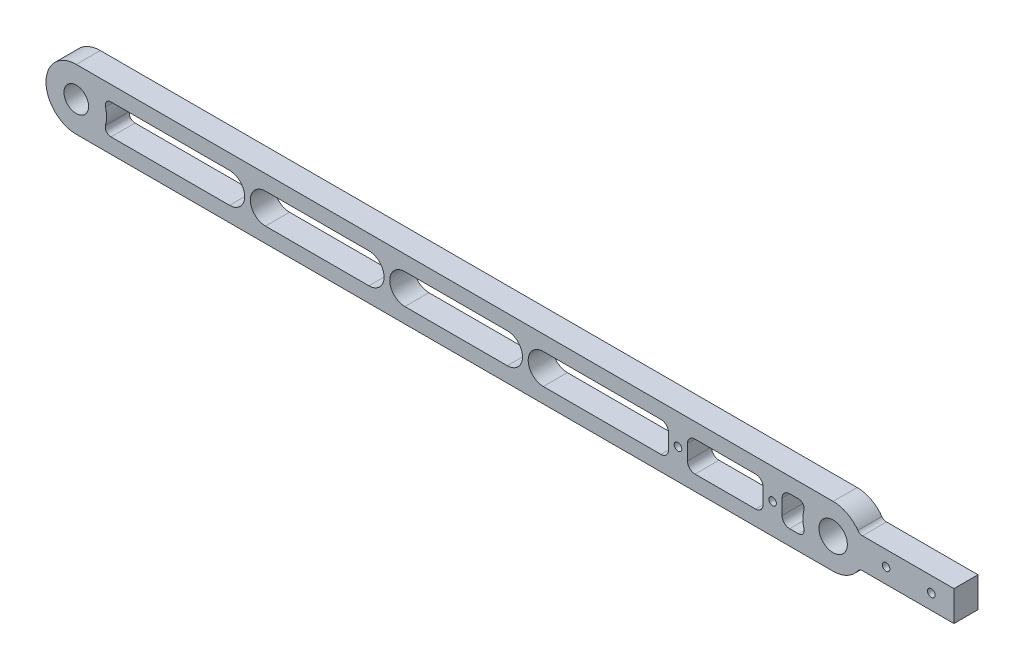
from build123d import *

# Parameters (mm, degrees)
SKETCH1_R           = 1
SKETCH1_R_2         = 3.25
SKETCH1_R_3         = 3.75
BOSS_EXTRUDE1_DEPTH = 6.35


with BuildPart() as part:
    # Sketch1 → Boss-Extrude1 (new body)
    with BuildSketch(Plane(origin=(0, 0, 0), x_dir=(-1, 0, 0), z_dir=(0, 0, -1))):
        with BuildLine():
            Line((0, 8), (-200, 8))
            ThreePointArc((-200, 8), (-203.670651742, 7.108186533), (-206.52291932, 4.631578948))
            ThreePointArc((-206.52291932, 4.631578948), (-207.05771949, 4.167215025), (-207.745966692, 4))
            Line((-207.745966692, 4), (-231.92820323, 4))
            Line((-231.92820323, 4), (-231.92820323, -4))
            Line((-231.92820323, -4), (-207.745966692, -4))
            ThreePointArc((-207.745966692, -4), (-207.05771949, -4.167215025), (-206.52291932, -4.631578947))
            ThreePointArc((-206.52291932, -4.631578947), (-203.670651742, -7.108186533), (-200, -8))
            Line((-200, -8), (0, -8))
            ThreePointArc((0, -8), (8, 0), (0, 8))
        make_face()
        with Locations((-159, 0)):
            Circle(SKETCH1_R, mode=Mode.SUBTRACT)
        with Locations((-184, 0)):
            Circle(SKETCH1_R, mode=Mode.SUBTRACT)
        Circle(SKETCH1_R_2, mode=Mode.SUBTRACT)
        with Locations((-200, 0)):
            Circle(SKETCH1_R_3, mode=Mode.SUBTRACT)
        with Locations((-213.982050808, 0)):
            Circle(SKETCH1_R, mode=Mode.SUBTRACT)
        with Locations((-225.946152423, 0)):
            Circle(SKETCH1_R, mode=Mode.SUBTRACT)
        with BuildLine():
            Line((-186.499999983, 1.999999984), (-186.499999983, -1.999999983))
            ThreePointArc((-186.499999983, -1.999999983), (-187.085786426, -3.414213557), (-188.5, -4))
            Line((-188.5, -4), (-190.83484861, -4))
            ThreePointArc((-190.83484861, -4), (-192.026927731, -3.410465468), (-192.281977777, -2.105263158))
            ThreePointArc((-192.281977777, -2.105263158), (-192, 0), (-192.281977777, 2.105263158))
            ThreePointArc((-192.281977777, 2.105263158), (-192.026927731, 3.410465468), (-190.83484861, 4))
            Line((-190.83484861, 4), (-188.5, 4))
            ThreePointArc((-188.5, 4), (-187.085786426, 3.414213558), (-186.499999983, 1.999999984))
        make_face(mode=Mode.SUBTRACT)
        with BuildLine():
            Line((-181.499999977, -2.000000023), (-181.499999977, 2.000000023))
            ThreePointArc((-181.499999977, 2.000000023), (-180.914213546, 3.414213569), (-179.5, 4))
            Line((-179.5, 4), (-163.5, 4))
            ThreePointArc((-163.5, 4), (-162.085786447, 3.414213567), (-161.500000014, 2.000000014))
            Line((-161.500000014, 2.000000014), (-161.500000014, -2.000000014))
            ThreePointArc((-161.500000014, -2.000000014), (-162.085786447, -3.414213566), (-163.5, -4))
            Line((-163.5, -4), (-179.5, -4))
            ThreePointArc((-179.5, -4), (-180.914213546, -3.414213569), (-181.499999977, -2.000000023))
        make_face(mode=Mode.SUBTRACT)
        with BuildLine():
            Line((-49.998863542, -4), (-77.332575695, -4))
            ThreePointArc((-77.332575695, -4), (-81.332575695, 0), (-77.332575695, 4))
            Line((-77.332575695, 4), (-49.998863542, 4))
            ThreePointArc((-49.998863542, 4), (-45.998863542, 0), (-49.998863542, -4))
        make_face(mode=Mode.SUBTRACT)
        with BuildLine():
            Line((-123.416287847, -4), (-154.5, -4))
            ThreePointArc((-154.5, -4), (-155.914213568, -3.41421356), (-156.500000008, -1.999999992))
            Line((-156.500000008, -1.999999992), (-156.500000008, 1.999999992))
            ThreePointArc((-156.500000008, 1.999999992), (-155.914213568, 3.41421356), (-154.5, 4))
            Line((-154.5, 4), (-123.416287847, 4))
            ThreePointArc((-123.416287847, 4), (-119.416287847, 0), (-123.416287847, -4))
        make_face(mode=Mode.SUBTRACT)
        with BuildLine():
            Line((-113.916287847, 4), (-86.832575695, 4))
            ThreePointArc((-86.832575695, 4), (-82.832575695, 0), (-86.832575695, -4))
            Line((-86.832575695, -4), (-113.916287847, -4))
            ThreePointArc((-113.916287847, -4), (-117.916287847, 0), (-113.916287847, 4))
        make_face(mode=Mode.SUBTRACT)
        with BuildLine():
            Line((-40.498863542, 4), (-9.16515139, 4))
            ThreePointArc((-9.16515139, 4), (-7.973072268, 3.410465468), (-7.718022223, 2.105263158))
            ThreePointArc((-7.718022223, 2.105263158), (-8, 0), (-7.718022223, -2.105263158))
            ThreePointArc((-7.718022223, -2.105263158), (-7.973072268, -3.410465468), (-9.16515139, -4))
            Line((-9.16515139, -4), (-40.498863542, -4))
            ThreePointArc((-40.498863542, -4), (-44.498863542, 0), (-40.498863542, 4))
        make_face(mode=Mode.SUBTRACT)
    extrude(amount=-BOSS_EXTRUDE1_DEPTH)


solid = part.part
